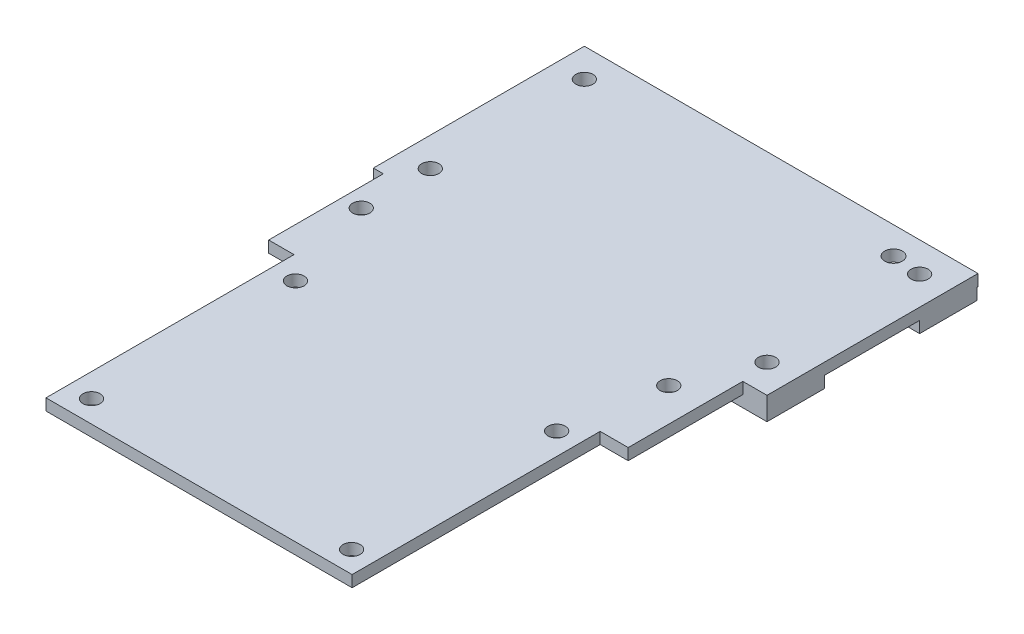
from build123d import *

# Parameters (mm, degrees)
SKETCH1_W             = 10
SKETCH1_H             = 10
SKETCH1_R             = 1.5
BOSS_EXTRUDE1_DEPTH   = 2
BOSS_EXTRUDE1_2_DEPTH = 2
BOSS_EXTRUDE1_3_DEPTH = 2
BOSS_EXTRUDE1_4_DEPTH = 2
SKETCH2_W             = 68.718732211
SKETCH2_H             = 36.837925628
SKETCH2_R             = 1.5
BOSS_EXTRUDE2_DEPTH   = 2
SKETCH3_W             = 62.76
SKETCH3_H             = 45
SKETCH3_R             = 1.5
BOSS_EXTRUDE3_DEPTH   = 2
SKETCH4_R             = 1.5
CUT_EXTRUDE1_DEPTH    = 2
SKETCH5_R             = 1.5
CUT_EXTRUDE2_DEPTH    = 2
SKETCH6_R             = 1.538732211
CUT_EXTRUDE3_DEPTH    = 4
SKETCH7_W             = 53.44
SKETCH7_H             = 43.3
SKETCH7_R             = 1.5
BOSS_EXTRUDE4_DEPTH   = 2


with BuildPart() as part:
    # Sketch1 → Boss-Extrude1 (new body)
    with BuildSketch(Plane(origin=(0, 0, 0), x_dir=(1, 0, 0), z_dir=(0, 1, 0))):
        with Locations((-68.417052022, 33.167885028)):
            Rectangle(SKETCH1_W, SKETCH1_H)
        with Locations((-68.417052022, 33.167885028)):
            Circle(SKETCH1_R, mode=Mode.SUBTRACT)
    extrude(amount=BOSS_EXTRUDE1_DEPTH)



with BuildPart() as body_2:
    # Sketch1 → Boss-Extrude1 2 (new body)
    with BuildSketch(Plane(origin=(0, 0, 0), x_dir=(1, 0, 0), z_dir=(0, 1, 0))):
        with Locations((-68.356859369, 6.212274972)):
            Rectangle(SKETCH1_W, SKETCH1_H)
        with Locations((-68.356859369, 6.212274972)):
            Circle(SKETCH1_R, mode=Mode.SUBTRACT)
    extrude(amount=BOSS_EXTRUDE1_2_DEPTH)


with BuildPart() as body_3:
    # Sketch1 → Boss-Extrude1 3 (new body)
    with BuildSketch(Plane(origin=(0, 0, 0), x_dir=(1, 0, 0), z_dir=(0, 1, 0))):
        with Locations((-9.698319811, 6.3299594)):
            Rectangle(SKETCH1_W, SKETCH1_H)
        with Locations((-9.698319811, 6.3299594)):
            Circle(SKETCH1_R, mode=Mode.SUBTRACT)
    extrude(amount=BOSS_EXTRUDE1_3_DEPTH)


with BuildPart() as body_4:
    # Sketch1 → Boss-Extrude1 4 (new body)
    with BuildSketch(Plane(origin=(0, 0, 0), x_dir=(1, 0, 0), z_dir=(0, 1, 0))):
        with Locations((-9.698319811, 32.974349344)):
            Rectangle(SKETCH1_W, SKETCH1_H)
        with Locations((-9.698319811, 32.974349344)):
            Circle(SKETCH1_R, mode=Mode.SUBTRACT)
    extrude(amount=BOSS_EXTRUDE1_4_DEPTH)


with BuildPart() as part_1:
    add(part.part)

    add(body_2.part)  # Boss-Extrude2 merges body 2

    add(body_3.part)  # Boss-Extrude2 merges body 3

    add(body_4.part)  # Boss-Extrude2 merges body 4
    # Sketch2 → Boss-Extrude2 (add)
    with BuildSketch(Plane(origin=(0, 2, 0), x_dir=(1, 0, 0), z_dir=(0, 1, 0))):
        with Locations((-39.057685917, 19.748922214)):
            Rectangle(SKETCH2_W, SKETCH2_H)
        with Locations((-68.417052022, 33.167885028)):
            Circle(SKETCH2_R, mode=Mode.SUBTRACT)
        with Locations((-9.698319811, 32.974349344)):
            Circle(SKETCH2_R, mode=Mode.SUBTRACT)
        with Locations((-9.698319811, 6.3299594)):
            Circle(SKETCH2_R, mode=Mode.SUBTRACT)
        with Locations((-68.356859369, 6.212274972)):
            Circle(SKETCH2_R, mode=Mode.SUBTRACT)
    extrude(amount=BOSS_EXTRUDE2_DEPTH)

    # Sketch3 → Boss-Extrude3 (add)
    with BuildSketch(Plane(origin=(0, 4, 0), x_dir=(1, 0, 0), z_dir=(0, 1, 0))):
        with Locations((-40.297052022, 13.817885028)):
            Rectangle(SKETCH3_W, SKETCH3_H)
        with Locations((-68.417052022, 33.167885028)):
            Circle(SKETCH3_R, mode=Mode.SUBTRACT)
        with Locations((-68.356859369, 6.212274972)):
            Circle(SKETCH3_R, mode=Mode.SUBTRACT)
    extrude(amount=-BOSS_EXTRUDE3_DEPTH)

    # Sketch4 → Cut-Extrude1 (cut)
    with BuildSketch(Plane(origin=(0, 4, 0), x_dir=(1, 0, 0), z_dir=(0, 1, 0))):
        with Locations((-9.698319811, 6.3299594)):
            Circle(SKETCH4_R)
        with Locations((-9.698319811, 32.974349344)):
            Circle(SKETCH4_R)
    extrude(amount=-CUT_EXTRUDE1_DEPTH, mode=Mode.SUBTRACT)

    # Sketch5 → Cut-Extrude2 (cut)
    with BuildSketch(Plane(origin=(0, 4, 0), x_dir=(1, 0, 0), z_dir=(0, 1, 0))):
        with Locations((-68.417052022, -5.782114972)):
            Circle(SKETCH5_R)
        with Locations((-14.737052022, -5.782114972)):
            Circle(SKETCH5_R)
        with Locations((-14.737052022, 33.417885028)):
            Circle(SKETCH5_R)
    extrude(amount=-CUT_EXTRUDE2_DEPTH, mode=Mode.SUBTRACT)

    # Sketch6 → Cut-Extrude3 (cut)
    with BuildSketch(Plane(origin=(0, 4, 0), x_dir=(1, 0, 0), z_dir=(0, 1, 0))):
        with Locations((-14.698319811, 33.417885028)):
            Circle(SKETCH6_R)
    extrude(amount=-CUT_EXTRUDE3_DEPTH, mode=Mode.SUBTRACT)

    # Sketch7 → Boss-Extrude4 (add)
    with BuildSketch(Plane(origin=(0, 4, 0), x_dir=(1, 0, 0), z_dir=(0, 1, 0))):
        with Locations((-40.531724845, -40.332114972)):
            Rectangle(SKETCH7_W, SKETCH7_H)
        with Locations((-63.151724845, -22.532114972)):
            Circle(SKETCH7_R, mode=Mode.SUBTRACT)
        with Locations((-63.151724845, -58.132114972)):
            Circle(SKETCH7_R, mode=Mode.SUBTRACT)
        with Locations((-17.651724845, -58.232114972)):
            Circle(SKETCH7_R, mode=Mode.SUBTRACT)
        with Locations((-17.651724845, -22.432114972)):
            Circle(SKETCH7_R, mode=Mode.SUBTRACT)
        Polygon((-71.677052022, -18.682114972), (-67.251724845, -18.682114972), (-13.811724845, -18.682114972), (-8.917052022, -18.682114972), (-8.917052022, -8.682114972), (-71.677052022, -8.682114972), align=None)
    extrude(amount=-BOSS_EXTRUDE4_DEPTH)


solid = part_1.part
